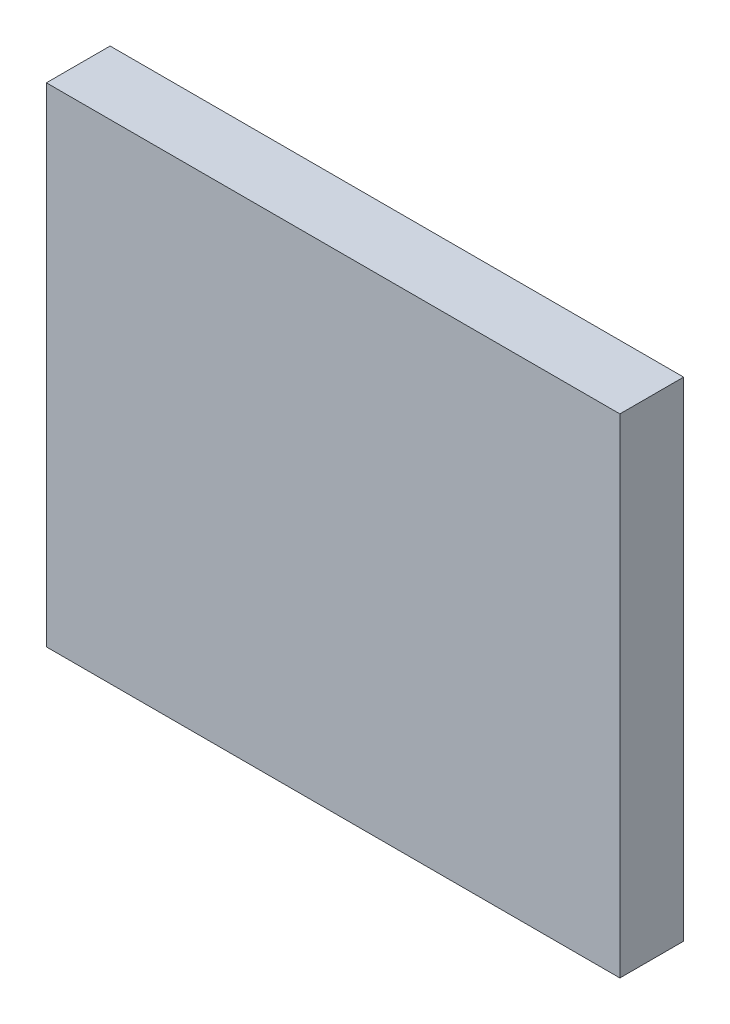
from build123d import *

# Parameters (mm, degrees)
ESQUISSE1_W        = 27
ESQUISSE1_H        = 23
BOSS_EXTRU_1_DEPTH = 3


with BuildPart() as part:
    # Esquisse1 → Boss.-Extru.1 (new body)
    with BuildSketch(Plane.XY):
        Rectangle(ESQUISSE1_W, ESQUISSE1_H)
    extrude(amount=BOSS_EXTRU_1_DEPTH)


solid = part.part
